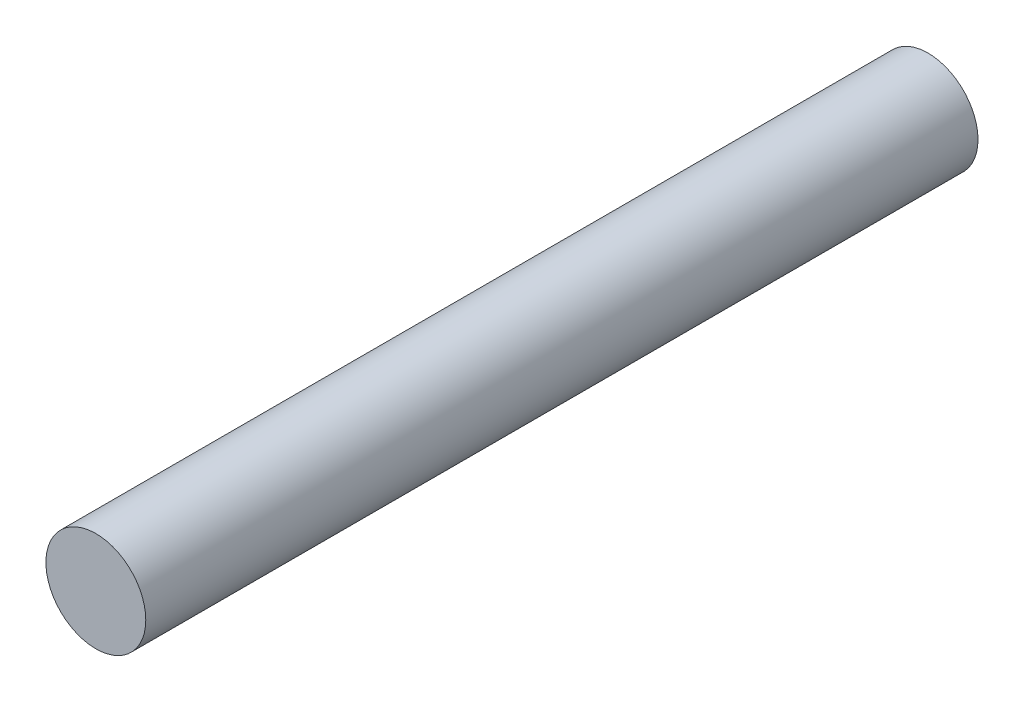
from build123d import *

# Parameters (mm, degrees)
SKETCH_1_R      = 3
EXTRUDE_1_DEPTH = 50


with BuildPart() as part:
    # 草图1 → 凸台-拉伸1 (new body)
    with BuildSketch(Plane.XY):
        Circle(SKETCH_1_R)
    extrude(amount=EXTRUDE_1_DEPTH)


solid = part.part
